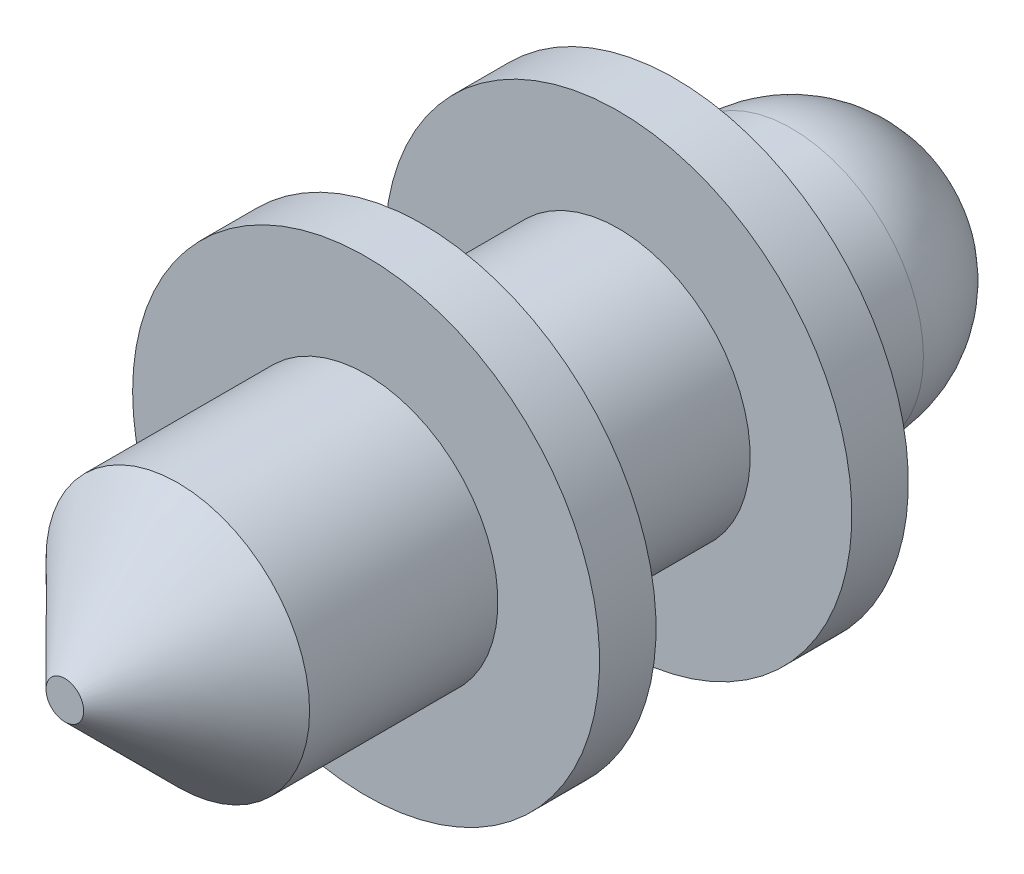
from build123d import *

# Parameters (mm, degrees)
ESQUISSE1_R        = 1.75
BOSS_EXTRU_1_DEPTH = 4
ESQUISSE3_R        = 3.1
BOSS_EXTRU_2_DEPTH = 0.75
ESQUISSE4_R        = 1.75
BOSS_EXTRU_3_DEPTH = 2.6
ESQUISSE5_R        = 3.1
BOSS_EXTRU_4_DEPTH = 0.75
ESQUISSE6_R        = 1.75
BOSS_EXTRU_5_DEPTH = 3.3
CHANFREIN1_SIZE    = 1.5
CONG_1_R           = 1.75


with BuildPart() as part:
    # Esquisse1 → Boss.-Extru.1 (new body)
    with BuildSketch(Plane.XY):
        Circle(ESQUISSE1_R)
    extrude(amount=BOSS_EXTRU_1_DEPTH)

    # Esquisse3 → Boss.-Extru.2 (add)
    with BuildSketch(Plane(origin=(0, 0, 0), x_dir=(-1, 0, 0), z_dir=(0, 0, -1))):
        Circle(ESQUISSE3_R)
    extrude(amount=BOSS_EXTRU_2_DEPTH)

    # Esquisse4 → Boss.-Extru.3 (add)
    with BuildSketch(Plane(origin=(0, 0, -0.75), x_dir=(-1, 0, 0), z_dir=(0, 0, -1))):
        Circle(ESQUISSE4_R)
    extrude(amount=BOSS_EXTRU_3_DEPTH)

    # Esquisse5 → Boss.-Extru.4 (add)
    with BuildSketch(Plane(origin=(0, 0, -3.35), x_dir=(-1, 0, 0), z_dir=(0, 0, -1))):
        Circle(ESQUISSE5_R)
    extrude(amount=BOSS_EXTRU_4_DEPTH)

    # Esquisse6 → Boss.-Extru.5 (add)
    with BuildSketch(Plane(origin=(0, 0, -4.1), x_dir=(-1, 0, 0), z_dir=(0, 0, -1))):
        Circle(ESQUISSE6_R)
    extrude(amount=BOSS_EXTRU_5_DEPTH)

    # Chanfrein1
    chanfrein1_edges = [part.edges().sort_by_distance(p)[0] for p in [
        (-1.75, 0, 4),
    ]]
    chamfer(chanfrein1_edges, length=CHANFREIN1_SIZE)

    # Congé1
    cong_1_edges = [part.edges().sort_by_distance(p)[0] for p in [
        (1.75, 0, -7.4),
    ]]
    fillet(cong_1_edges, radius=CONG_1_R)


solid = part.part
